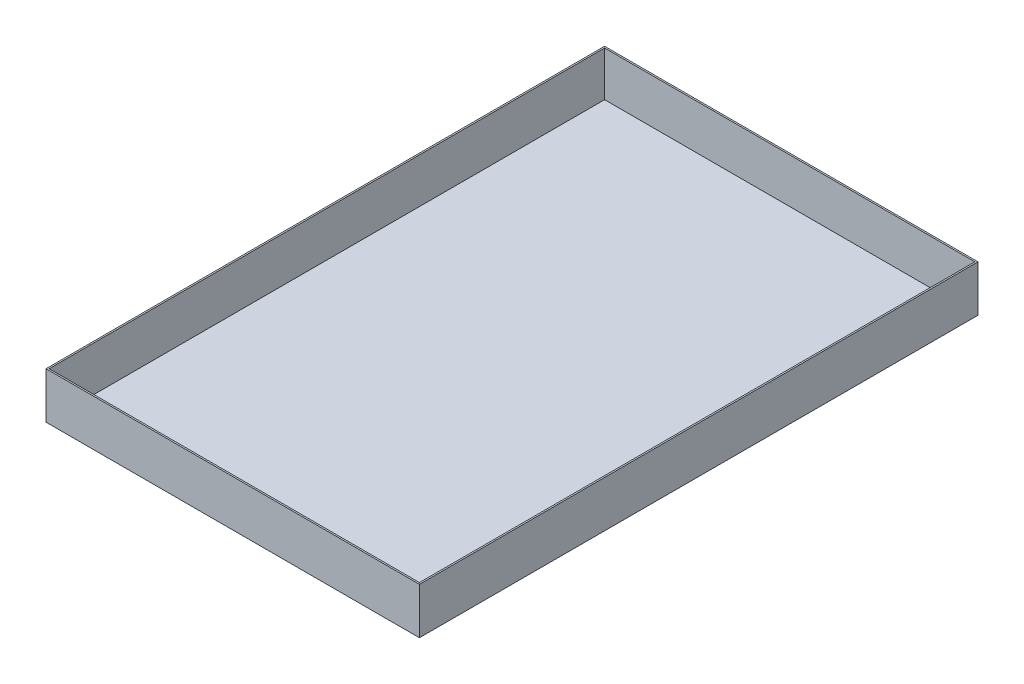
from build123d import *

# Parameters (mm, degrees)
SKETCH1_W           = 614.68
SKETCH1_H           = 919.48
BOSS_EXTRUDE1_DEPTH = 76.2
SHELL1_T            = -2.54


with BuildPart() as part:
    # Sketch1 → Boss-Extrude1 (new body)
    with BuildSketch(Plane(origin=(0, 0, 0), x_dir=(1, 0, 0), z_dir=(0, 1, 0))):
        with Locations((307.34, 459.74)):
            Rectangle(SKETCH1_W, SKETCH1_H)
    extrude(amount=BOSS_EXTRUDE1_DEPTH)

    # Shell1
    shell1_openings = [part.faces().sort_by_distance(p)[0] for p in [
        (307.34, 76.2, -459.74),
    ]]
    offset(amount=SHELL1_T, openings=shell1_openings, kind=Kind.INTERSECTION)


solid = part.part
